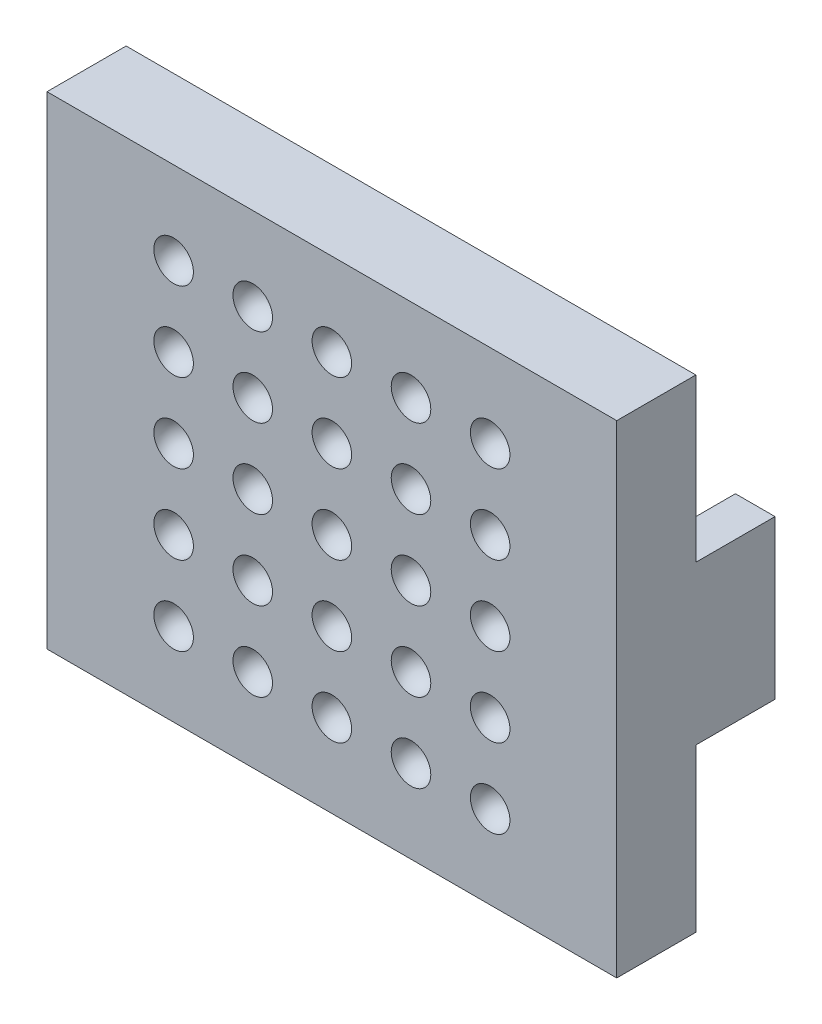
from build123d import *

# Parameters (mm, degrees)
SKETCH1_W                  = 72
SKETCH1_H                  = 61
MOLD_TOP_DEPTH             = 10
SKETCH3_W                  = 5
SKETCH3_H                  = 20
HANDLE_1_DEPTH             = 10
LPATTERN1_COUNT            = 3
LPATTERN1_PITCH            = 10
LPATTERN1_COUNT_DIR2       = 3
LPATTERN1_PITCH_DIR2       = 10
LPATTERN2_COUNT            = 3
LPATTERN2_PITCH            = 10
LPATTERN2_COUNT_DIR2       = 3
LPATTERN2_PITCH_DIR2       = 10
SKETCH6_R                  = 0.5
CUT_EXTRUDE1_DEPTH         = 21
LPATTERN3_COUNT            = 3
LPATTERN3_PITCH            = 10
LPATTERN3_COUNT_DIR2       = 3
LPATTERN3_PITCH_DIR2       = 10
LPATTERN4_COUNT            = 3
LPATTERN4_PITCH            = 10
LPATTERN4_COUNT_DIR2       = 3
LPATTERN4_PITCH_DIR2       = 10
LPATTERN4_COPY_1_SKETCH_R  = 0.5
LPATTERN4_COPY_1_DEPTH     = 21
LPATTERN4_COPY_2_SKETCH_R  = 0.5
LPATTERN4_COPY_2_DEPTH     = 21
LPATTERN4_COPY_3_SKETCH_R  = 0.5
LPATTERN4_COPY_3_DEPTH     = 21
LPATTERN4_COPY_4_SKETCH_R  = 0.5
LPATTERN4_COPY_4_DEPTH     = 21
LPATTERN4_COPY_5_SKETCH_R  = 0.5
LPATTERN4_COPY_5_DEPTH     = 21
LPATTERN4_COPY_6_SKETCH_R  = 0.5
LPATTERN4_COPY_6_DEPTH     = 21
LPATTERN4_COPY_7_SKETCH_R  = 0.5
LPATTERN4_COPY_7_DEPTH     = 21
LPATTERN4_COPY_8_SKETCH_R  = 0.5
LPATTERN4_COPY_8_DEPTH     = 21
LPATTERN4_COPY_9_SKETCH_R  = 0.5
LPATTERN4_COPY_9_DEPTH     = 21
LPATTERN4_COPY_10_SKETCH_R = 0.5
LPATTERN4_COPY_10_DEPTH    = 21
LPATTERN4_COPY_11_SKETCH_R = 0.5
LPATTERN4_COPY_11_DEPTH    = 21
LPATTERN4_COPY_12_SKETCH_R = 0.5
LPATTERN4_COPY_12_DEPTH    = 21
LPATTERN4_COPY_13_SKETCH_R = 0.5
LPATTERN4_COPY_13_DEPTH    = 21
LPATTERN4_COPY_14_SKETCH_R = 0.5
LPATTERN4_COPY_14_DEPTH    = 21
LPATTERN4_COPY_15_SKETCH_R = 0.5
LPATTERN4_COPY_15_DEPTH    = 21
LPATTERN4_COPY_16_SKETCH_R = 0.5
LPATTERN4_COPY_16_DEPTH    = 21
LPATTERN4_COPY_17_SKETCH_R = 0.5
LPATTERN4_COPY_17_DEPTH    = 21
LPATTERN4_COPY_18_SKETCH_R = 0.5
LPATTERN4_COPY_18_DEPTH    = 21
LPATTERN4_COPY_19_SKETCH_R = 0.5
LPATTERN4_COPY_19_DEPTH    = 21
LPATTERN4_COPY_20_SKETCH_R = 0.5
LPATTERN4_COPY_20_DEPTH    = 21
LPATTERN4_COPY_21_SKETCH_R = 0.5
LPATTERN4_COPY_21_DEPTH    = 21
LPATTERN4_COPY_22_SKETCH_R = 0.5
LPATTERN4_COPY_22_DEPTH    = 21
LPATTERN4_COPY_23_SKETCH_R = 0.5
LPATTERN4_COPY_23_DEPTH    = 21
LPATTERN4_COPY_24_SKETCH_R = 0.5
LPATTERN4_COPY_24_DEPTH    = 21
LPATTERN4_COPY_25_SKETCH_R = 0.5
LPATTERN4_COPY_25_DEPTH    = 21
LPATTERN4_COPY_26_SKETCH_R = 0.5
LPATTERN4_COPY_26_DEPTH    = 21
LPATTERN4_COPY_27_SKETCH_R = 0.5
LPATTERN4_COPY_27_DEPTH    = 21
LPATTERN4_COPY_28_SKETCH_R = 0.5
LPATTERN4_COPY_28_DEPTH    = 21
LPATTERN4_COPY_29_SKETCH_R = 0.5
LPATTERN4_COPY_29_DEPTH    = 21
LPATTERN4_COPY_30_SKETCH_R = 0.5
LPATTERN4_COPY_30_DEPTH    = 21
LPATTERN4_COPY_31_SKETCH_R = 0.5
LPATTERN4_COPY_31_DEPTH    = 21
LPATTERN4_COPY_32_SKETCH_R = 0.5
LPATTERN4_COPY_32_DEPTH    = 21
LPATTERN4_COPY_33_SKETCH_R = 0.5
LPATTERN4_COPY_33_DEPTH    = 21
LPATTERN4_COPY_34_SKETCH_R = 0.5
LPATTERN4_COPY_34_DEPTH    = 21
LPATTERN4_COPY_35_SKETCH_R = 0.5
LPATTERN4_COPY_35_DEPTH    = 21
LPATTERN4_COPY_36_SKETCH_R = 0.5
LPATTERN4_COPY_36_DEPTH    = 21
LPATTERN4_COPY_37_SKETCH_R = 0.5
LPATTERN4_COPY_37_DEPTH    = 21
LPATTERN4_COPY_38_SKETCH_R = 0.5
LPATTERN4_COPY_38_DEPTH    = 21
LPATTERN4_COPY_39_SKETCH_R = 0.5
LPATTERN4_COPY_39_DEPTH    = 21
LPATTERN4_COPY_40_SKETCH_R = 0.5
LPATTERN4_COPY_40_DEPTH    = 21
LPATTERN4_COPY_41_SKETCH_R = 0.5
LPATTERN4_COPY_41_DEPTH    = 21
LPATTERN4_COPY_42_SKETCH_R = 0.5
LPATTERN4_COPY_42_DEPTH    = 21
LPATTERN4_COPY_43_SKETCH_R = 0.5
LPATTERN4_COPY_43_DEPTH    = 21
LPATTERN4_COPY_44_SKETCH_R = 0.5
LPATTERN4_COPY_44_DEPTH    = 21
LPATTERN4_COPY_45_SKETCH_R = 0.5
LPATTERN4_COPY_45_DEPTH    = 21
LPATTERN4_COPY_46_SKETCH_R = 0.5
LPATTERN4_COPY_46_DEPTH    = 21
LPATTERN4_COPY_47_SKETCH_R = 0.5
LPATTERN4_COPY_47_DEPTH    = 21
LPATTERN4_COPY_48_SKETCH_R = 0.5
LPATTERN4_COPY_48_DEPTH    = 21
LPATTERN4_COPY_49_SKETCH_R = 0.5
LPATTERN4_COPY_49_DEPTH    = 21
LPATTERN4_COPY_50_SKETCH_R = 0.5
LPATTERN4_COPY_50_DEPTH    = 21
LPATTERN4_COPY_51_SKETCH_R = 0.5
LPATTERN4_COPY_51_DEPTH    = 21
LPATTERN4_COPY_52_SKETCH_R = 0.5
LPATTERN4_COPY_52_DEPTH    = 21
LPATTERN4_COPY_53_SKETCH_R = 0.5
LPATTERN4_COPY_53_DEPTH    = 21
LPATTERN4_COPY_54_SKETCH_R = 0.5
LPATTERN4_COPY_54_DEPTH    = 21
LPATTERN4_COPY_55_SKETCH_R = 0.5
LPATTERN4_COPY_55_DEPTH    = 21
LPATTERN4_COPY_56_SKETCH_R = 0.5
LPATTERN4_COPY_56_DEPTH    = 21
LPATTERN4_COPY_57_SKETCH_R = 0.5
LPATTERN4_COPY_57_DEPTH    = 21
LPATTERN4_COPY_58_SKETCH_R = 0.5
LPATTERN4_COPY_58_DEPTH    = 21
LPATTERN4_COPY_59_SKETCH_R = 0.5
LPATTERN4_COPY_59_DEPTH    = 21
LPATTERN4_COPY_60_SKETCH_R = 0.5
LPATTERN4_COPY_60_DEPTH    = 21
LPATTERN4_COPY_61_SKETCH_R = 0.5
LPATTERN4_COPY_61_DEPTH    = 21
LPATTERN4_COPY_62_SKETCH_R = 0.5
LPATTERN4_COPY_62_DEPTH    = 21
LPATTERN4_COPY_63_SKETCH_R = 0.5
LPATTERN4_COPY_63_DEPTH    = 21
LPATTERN4_COPY_64_SKETCH_R = 0.5
LPATTERN4_COPY_64_DEPTH    = 21


with BuildPart() as part:
    # Sketch1 → Mold Top (new body)
    with BuildSketch(Plane.XY):
        Rectangle(SKETCH1_W, SKETCH1_H)
    extrude(amount=MOLD_TOP_DEPTH)

    # Sketch3 → Handle 1 (add)
    with BuildSketch(Plane(origin=(0, 0, 0), x_dir=(-1, 0, 0), z_dir=(0, 0, -1))):
        with Locations((-33.5, 0)):
            Rectangle(SKETCH3_W, SKETCH3_H)
    handle_1 = extrude(amount=HANDLE_1_DEPTH)

    # Handle 2: Handle 1 across plane
    add(handle_1.mirror(Plane(origin=(0, 0, 0), x_dir=(0, 0, 1), z_dir=(1, 0, 0))))

    # Sketch5 → Cut-Revolve1 (revolve, cut)
    with BuildSketch(Plane.XY.offset(10)):
        with BuildLine():
            Line((0, 2.5), (0, -2.5))
            ThreePointArc((0, -2.5), (2.5, 0), (0, 2.5))
        make_face()
    cut_revolve1 = revolve(axis=Axis((0, 2.5, 10), (0, -1, 0)), mode=Mode.SUBTRACT)

    # LPattern1: Cut-Revolve1 3 × 3
    with Locations(*[(-j * LPATTERN1_PITCH_DIR2, -i * LPATTERN1_PITCH, 0) for i in range(LPATTERN1_COUNT) for j in range(LPATTERN1_COUNT_DIR2) if (i, j) != (0, 0)]):
        add(cut_revolve1, mode=Mode.SUBTRACT)

    # LPattern2: Cut-Revolve1 3 × 3
    with Locations(*[(i * LPATTERN2_PITCH, j * LPATTERN2_PITCH_DIR2, 0) for i in range(LPATTERN2_COUNT) for j in range(LPATTERN2_COUNT_DIR2) if (i, j) != (0, 0)]):
        add(cut_revolve1, mode=Mode.SUBTRACT)

    # LPattern2 copy 1 sketch → LPattern2 copy 1 (revolve, cut)
    with BuildSketch(Plane(origin=(-10, 10, 10), x_dir=(1, 0, 0), z_dir=(0, 0, 1))):
        with BuildLine():
            Line((0, 2.5), (0, -2.5))
            ThreePointArc((0, -2.5), (2.5, 0), (0, 2.5))
        make_face()
    revolve(axis=Axis((-10, 12.5, 10), (0, -1, 0)), mode=Mode.SUBTRACT)

    # LPattern2 copy 2 sketch → LPattern2 copy 2 (revolve, cut)
    with BuildSketch(Plane(origin=(-10, 20, 10), x_dir=(1, 0, 0), z_dir=(0, 0, 1))):
        with BuildLine():
            Line((0, 2.5), (0, -2.5))
            ThreePointArc((0, -2.5), (2.5, 0), (0, 2.5))
        make_face()
    revolve(axis=Axis((-10, 22.5, 10), (0, -1, 0)), mode=Mode.SUBTRACT)

    # LPattern2 copy 3 sketch → LPattern2 copy 3 (revolve, cut)
    with BuildSketch(Plane.XY.offset(10)):
        with BuildLine():
            Line((0, 2.5), (0, -2.5))
            ThreePointArc((0, -2.5), (2.5, 0), (0, 2.5))
        make_face()
    revolve(axis=Axis((0, 2.5, 10), (0, -1, 0)), mode=Mode.SUBTRACT)

    # LPattern2 copy 4 sketch → LPattern2 copy 4 (revolve, cut)
    with BuildSketch(Plane(origin=(0, 10, 10), x_dir=(1, 0, 0), z_dir=(0, 0, 1))):
        with BuildLine():
            Line((0, 2.5), (0, -2.5))
            ThreePointArc((0, -2.5), (2.5, 0), (0, 2.5))
        make_face()
    revolve(axis=Axis((0, 12.5, 10), (0, -1, 0)), mode=Mode.SUBTRACT)

    # LPattern2 copy 5 sketch → LPattern2 copy 5 (revolve, cut)
    with BuildSketch(Plane(origin=(0, 20, 10), x_dir=(1, 0, 0), z_dir=(0, 0, 1))):
        with BuildLine():
            Line((0, 2.5), (0, -2.5))
            ThreePointArc((0, -2.5), (2.5, 0), (0, 2.5))
        make_face()
    revolve(axis=Axis((0, 22.5, 10), (0, -1, 0)), mode=Mode.SUBTRACT)

    # LPattern2 copy 6 sketch → LPattern2 copy 6 (revolve, cut)
    with BuildSketch(Plane(origin=(10, 0, 10), x_dir=(1, 0, 0), z_dir=(0, 0, 1))):
        with BuildLine():
            Line((0, 2.5), (0, -2.5))
            ThreePointArc((0, -2.5), (2.5, 0), (0, 2.5))
        make_face()
    revolve(axis=Axis((10, 2.5, 10), (0, -1, 0)), mode=Mode.SUBTRACT)

    # LPattern2 copy 7 sketch → LPattern2 copy 7 (revolve, cut)
    with BuildSketch(Plane(origin=(10, 10, 10), x_dir=(1, 0, 0), z_dir=(0, 0, 1))):
        with BuildLine():
            Line((0, 2.5), (0, -2.5))
            ThreePointArc((0, -2.5), (2.5, 0), (0, 2.5))
        make_face()
    revolve(axis=Axis((10, 12.5, 10), (0, -1, 0)), mode=Mode.SUBTRACT)

    # LPattern2 copy 8 sketch → LPattern2 copy 8 (revolve, cut)
    with BuildSketch(Plane(origin=(10, 20, 10), x_dir=(1, 0, 0), z_dir=(0, 0, 1))):
        with BuildLine():
            Line((0, 2.5), (0, -2.5))
            ThreePointArc((0, -2.5), (2.5, 0), (0, 2.5))
        make_face()
    revolve(axis=Axis((10, 22.5, 10), (0, -1, 0)), mode=Mode.SUBTRACT)

    # LPattern2 copy 9 sketch → LPattern2 copy 9 (revolve, cut)
    with BuildSketch(Plane(origin=(-20, 10, 10), x_dir=(1, 0, 0), z_dir=(0, 0, 1))):
        with BuildLine():
            Line((0, 2.5), (0, -2.5))
            ThreePointArc((0, -2.5), (2.5, 0), (0, 2.5))
        make_face()
    revolve(axis=Axis((-20, 12.5, 10), (0, -1, 0)), mode=Mode.SUBTRACT)

    # LPattern2 copy 10 sketch → LPattern2 copy 10 (revolve, cut)
    with BuildSketch(Plane(origin=(-20, 20, 10), x_dir=(1, 0, 0), z_dir=(0, 0, 1))):
        with BuildLine():
            Line((0, 2.5), (0, -2.5))
            ThreePointArc((0, -2.5), (2.5, 0), (0, 2.5))
        make_face()
    revolve(axis=Axis((-20, 22.5, 10), (0, -1, 0)), mode=Mode.SUBTRACT)

    # LPattern2 copy 11 sketch → LPattern2 copy 11 (revolve, cut)
    with BuildSketch(Plane(origin=(-10, 0, 10), x_dir=(1, 0, 0), z_dir=(0, 0, 1))):
        with BuildLine():
            Line((0, 2.5), (0, -2.5))
            ThreePointArc((0, -2.5), (2.5, 0), (0, 2.5))
        make_face()
    revolve(axis=Axis((-10, 2.5, 10), (0, -1, 0)), mode=Mode.SUBTRACT)

    # LPattern2 copy 12 sketch → LPattern2 copy 12 (revolve, cut)
    with BuildSketch(Plane(origin=(-10, 10, 10), x_dir=(1, 0, 0), z_dir=(0, 0, 1))):
        with BuildLine():
            Line((0, 2.5), (0, -2.5))
            ThreePointArc((0, -2.5), (2.5, 0), (0, 2.5))
        make_face()
    revolve(axis=Axis((-10, 12.5, 10), (0, -1, 0)), mode=Mode.SUBTRACT)

    # LPattern2 copy 13 sketch → LPattern2 copy 13 (revolve, cut)
    with BuildSketch(Plane(origin=(-10, 20, 10), x_dir=(1, 0, 0), z_dir=(0, 0, 1))):
        with BuildLine():
            Line((0, 2.5), (0, -2.5))
            ThreePointArc((0, -2.5), (2.5, 0), (0, 2.5))
        make_face()
    revolve(axis=Axis((-10, 22.5, 10), (0, -1, 0)), mode=Mode.SUBTRACT)

    # LPattern2 copy 14 sketch → LPattern2 copy 14 (revolve, cut)
    with BuildSketch(Plane.XY.offset(10)):
        with BuildLine():
            Line((0, 2.5), (0, -2.5))
            ThreePointArc((0, -2.5), (2.5, 0), (0, 2.5))
        make_face()
    revolve(axis=Axis((0, 2.5, 10), (0, -1, 0)), mode=Mode.SUBTRACT)

    # LPattern2 copy 15 sketch → LPattern2 copy 15 (revolve, cut)
    with BuildSketch(Plane(origin=(0, 10, 10), x_dir=(1, 0, 0), z_dir=(0, 0, 1))):
        with BuildLine():
            Line((0, 2.5), (0, -2.5))
            ThreePointArc((0, -2.5), (2.5, 0), (0, 2.5))
        make_face()
    revolve(axis=Axis((0, 12.5, 10), (0, -1, 0)), mode=Mode.SUBTRACT)

    # LPattern2 copy 16 sketch → LPattern2 copy 16 (revolve, cut)
    with BuildSketch(Plane(origin=(0, 20, 10), x_dir=(1, 0, 0), z_dir=(0, 0, 1))):
        with BuildLine():
            Line((0, 2.5), (0, -2.5))
            ThreePointArc((0, -2.5), (2.5, 0), (0, 2.5))
        make_face()
    revolve(axis=Axis((0, 22.5, 10), (0, -1, 0)), mode=Mode.SUBTRACT)

    # LPattern2 copy 17 sketch → LPattern2 copy 17 (revolve, cut)
    with BuildSketch(Plane.XY.offset(10)):
        with BuildLine():
            Line((0, 2.5), (0, -2.5))
            ThreePointArc((0, -2.5), (2.5, 0), (0, 2.5))
        make_face()
    revolve(axis=Axis((0, 2.5, 10), (0, -1, 0)), mode=Mode.SUBTRACT)

    # LPattern2 copy 18 sketch → LPattern2 copy 18 (revolve, cut)
    with BuildSketch(Plane(origin=(0, 10, 10), x_dir=(1, 0, 0), z_dir=(0, 0, 1))):
        with BuildLine():
            Line((0, 2.5), (0, -2.5))
            ThreePointArc((0, -2.5), (2.5, 0), (0, 2.5))
        make_face()
    revolve(axis=Axis((0, 12.5, 10), (0, -1, 0)), mode=Mode.SUBTRACT)

    # LPattern2 copy 19 sketch → LPattern2 copy 19 (revolve, cut)
    with BuildSketch(Plane(origin=(10, -10, 10), x_dir=(1, 0, 0), z_dir=(0, 0, 1))):
        with BuildLine():
            Line((0, 2.5), (0, -2.5))
            ThreePointArc((0, -2.5), (2.5, 0), (0, 2.5))
        make_face()
    revolve(axis=Axis((10, -7.5, 10), (0, -1, 0)), mode=Mode.SUBTRACT)

    # LPattern2 copy 20 sketch → LPattern2 copy 20 (revolve, cut)
    with BuildSketch(Plane(origin=(10, 0, 10), x_dir=(1, 0, 0), z_dir=(0, 0, 1))):
        with BuildLine():
            Line((0, 2.5), (0, -2.5))
            ThreePointArc((0, -2.5), (2.5, 0), (0, 2.5))
        make_face()
    revolve(axis=Axis((10, 2.5, 10), (0, -1, 0)), mode=Mode.SUBTRACT)

    # LPattern2 copy 21 sketch → LPattern2 copy 21 (revolve, cut)
    with BuildSketch(Plane(origin=(10, 10, 10), x_dir=(1, 0, 0), z_dir=(0, 0, 1))):
        with BuildLine():
            Line((0, 2.5), (0, -2.5))
            ThreePointArc((0, -2.5), (2.5, 0), (0, 2.5))
        make_face()
    revolve(axis=Axis((10, 12.5, 10), (0, -1, 0)), mode=Mode.SUBTRACT)

    # LPattern2 copy 22 sketch → LPattern2 copy 22 (revolve, cut)
    with BuildSketch(Plane(origin=(20, -10, 10), x_dir=(1, 0, 0), z_dir=(0, 0, 1))):
        with BuildLine():
            Line((0, 2.5), (0, -2.5))
            ThreePointArc((0, -2.5), (2.5, 0), (0, 2.5))
        make_face()
    revolve(axis=Axis((20, -7.5, 10), (0, -1, 0)), mode=Mode.SUBTRACT)

    # LPattern2 copy 23 sketch → LPattern2 copy 23 (revolve, cut)
    with BuildSketch(Plane(origin=(20, 0, 10), x_dir=(1, 0, 0), z_dir=(0, 0, 1))):
        with BuildLine():
            Line((0, 2.5), (0, -2.5))
            ThreePointArc((0, -2.5), (2.5, 0), (0, 2.5))
        make_face()
    revolve(axis=Axis((20, 2.5, 10), (0, -1, 0)), mode=Mode.SUBTRACT)

    # LPattern2 copy 24 sketch → LPattern2 copy 24 (revolve, cut)
    with BuildSketch(Plane(origin=(20, 10, 10), x_dir=(1, 0, 0), z_dir=(0, 0, 1))):
        with BuildLine():
            Line((0, 2.5), (0, -2.5))
            ThreePointArc((0, -2.5), (2.5, 0), (0, 2.5))
        make_face()
    revolve(axis=Axis((20, 12.5, 10), (0, -1, 0)), mode=Mode.SUBTRACT)

    # LPattern2 copy 25 sketch → LPattern2 copy 25 (revolve, cut)
    with BuildSketch(Plane(origin=(-10, 0, 10), x_dir=(1, 0, 0), z_dir=(0, 0, 1))):
        with BuildLine():
            Line((0, 2.5), (0, -2.5))
            ThreePointArc((0, -2.5), (2.5, 0), (0, 2.5))
        make_face()
    revolve(axis=Axis((-10, 2.5, 10), (0, -1, 0)), mode=Mode.SUBTRACT)

    # LPattern2 copy 26 sketch → LPattern2 copy 26 (revolve, cut)
    with BuildSketch(Plane(origin=(-10, 10, 10), x_dir=(1, 0, 0), z_dir=(0, 0, 1))):
        with BuildLine():
            Line((0, 2.5), (0, -2.5))
            ThreePointArc((0, -2.5), (2.5, 0), (0, 2.5))
        make_face()
    revolve(axis=Axis((-10, 12.5, 10), (0, -1, 0)), mode=Mode.SUBTRACT)

    # LPattern2 copy 27 sketch → LPattern2 copy 27 (revolve, cut)
    with BuildSketch(Plane(origin=(0, -10, 10), x_dir=(1, 0, 0), z_dir=(0, 0, 1))):
        with BuildLine():
            Line((0, 2.5), (0, -2.5))
            ThreePointArc((0, -2.5), (2.5, 0), (0, 2.5))
        make_face()
    revolve(axis=Axis((0, -7.5, 10), (0, -1, 0)), mode=Mode.SUBTRACT)

    # LPattern2 copy 28 sketch → LPattern2 copy 28 (revolve, cut)
    with BuildSketch(Plane.XY.offset(10)):
        with BuildLine():
            Line((0, 2.5), (0, -2.5))
            ThreePointArc((0, -2.5), (2.5, 0), (0, 2.5))
        make_face()
    revolve(axis=Axis((0, 2.5, 10), (0, -1, 0)), mode=Mode.SUBTRACT)

    # LPattern2 copy 29 sketch → LPattern2 copy 29 (revolve, cut)
    with BuildSketch(Plane(origin=(0, 10, 10), x_dir=(1, 0, 0), z_dir=(0, 0, 1))):
        with BuildLine():
            Line((0, 2.5), (0, -2.5))
            ThreePointArc((0, -2.5), (2.5, 0), (0, 2.5))
        make_face()
    revolve(axis=Axis((0, 12.5, 10), (0, -1, 0)), mode=Mode.SUBTRACT)

    # LPattern2 copy 30 sketch → LPattern2 copy 30 (revolve, cut)
    with BuildSketch(Plane(origin=(10, -10, 10), x_dir=(1, 0, 0), z_dir=(0, 0, 1))):
        with BuildLine():
            Line((0, 2.5), (0, -2.5))
            ThreePointArc((0, -2.5), (2.5, 0), (0, 2.5))
        make_face()
    revolve(axis=Axis((10, -7.5, 10), (0, -1, 0)), mode=Mode.SUBTRACT)

    # LPattern2 copy 31 sketch → LPattern2 copy 31 (revolve, cut)
    with BuildSketch(Plane(origin=(10, 0, 10), x_dir=(1, 0, 0), z_dir=(0, 0, 1))):
        with BuildLine():
            Line((0, 2.5), (0, -2.5))
            ThreePointArc((0, -2.5), (2.5, 0), (0, 2.5))
        make_face()
    revolve(axis=Axis((10, 2.5, 10), (0, -1, 0)), mode=Mode.SUBTRACT)

    # LPattern2 copy 32 sketch → LPattern2 copy 32 (revolve, cut)
    with BuildSketch(Plane(origin=(10, 10, 10), x_dir=(1, 0, 0), z_dir=(0, 0, 1))):
        with BuildLine():
            Line((0, 2.5), (0, -2.5))
            ThreePointArc((0, -2.5), (2.5, 0), (0, 2.5))
        make_face()
    revolve(axis=Axis((10, 12.5, 10), (0, -1, 0)), mode=Mode.SUBTRACT)

    # LPattern2 copy 33 sketch → LPattern2 copy 33 (revolve, cut)
    with BuildSketch(Plane(origin=(-20, 0, 10), x_dir=(1, 0, 0), z_dir=(0, 0, 1))):
        with BuildLine():
            Line((0, 2.5), (0, -2.5))
            ThreePointArc((0, -2.5), (2.5, 0), (0, 2.5))
        make_face()
    revolve(axis=Axis((-20, 2.5, 10), (0, -1, 0)), mode=Mode.SUBTRACT)

    # LPattern2 copy 34 sketch → LPattern2 copy 34 (revolve, cut)
    with BuildSketch(Plane(origin=(-20, 10, 10), x_dir=(1, 0, 0), z_dir=(0, 0, 1))):
        with BuildLine():
            Line((0, 2.5), (0, -2.5))
            ThreePointArc((0, -2.5), (2.5, 0), (0, 2.5))
        make_face()
    revolve(axis=Axis((-20, 12.5, 10), (0, -1, 0)), mode=Mode.SUBTRACT)

    # LPattern2 copy 35 sketch → LPattern2 copy 35 (revolve, cut)
    with BuildSketch(Plane(origin=(-10, -10, 10), x_dir=(1, 0, 0), z_dir=(0, 0, 1))):
        with BuildLine():
            Line((0, 2.5), (0, -2.5))
            ThreePointArc((0, -2.5), (2.5, 0), (0, 2.5))
        make_face()
    revolve(axis=Axis((-10, -7.5, 10), (0, -1, 0)), mode=Mode.SUBTRACT)

    # LPattern2 copy 36 sketch → LPattern2 copy 36 (revolve, cut)
    with BuildSketch(Plane(origin=(-10, 0, 10), x_dir=(1, 0, 0), z_dir=(0, 0, 1))):
        with BuildLine():
            Line((0, 2.5), (0, -2.5))
            ThreePointArc((0, -2.5), (2.5, 0), (0, 2.5))
        make_face()
    revolve(axis=Axis((-10, 2.5, 10), (0, -1, 0)), mode=Mode.SUBTRACT)

    # LPattern2 copy 37 sketch → LPattern2 copy 37 (revolve, cut)
    with BuildSketch(Plane(origin=(-10, 10, 10), x_dir=(1, 0, 0), z_dir=(0, 0, 1))):
        with BuildLine():
            Line((0, 2.5), (0, -2.5))
            ThreePointArc((0, -2.5), (2.5, 0), (0, 2.5))
        make_face()
    revolve(axis=Axis((-10, 12.5, 10), (0, -1, 0)), mode=Mode.SUBTRACT)

    # LPattern2 copy 38 sketch → LPattern2 copy 38 (revolve, cut)
    with BuildSketch(Plane(origin=(0, -10, 10), x_dir=(1, 0, 0), z_dir=(0, 0, 1))):
        with BuildLine():
            Line((0, 2.5), (0, -2.5))
            ThreePointArc((0, -2.5), (2.5, 0), (0, 2.5))
        make_face()
    revolve(axis=Axis((0, -7.5, 10), (0, -1, 0)), mode=Mode.SUBTRACT)

    # LPattern2 copy 39 sketch → LPattern2 copy 39 (revolve, cut)
    with BuildSketch(Plane.XY.offset(10)):
        with BuildLine():
            Line((0, 2.5), (0, -2.5))
            ThreePointArc((0, -2.5), (2.5, 0), (0, 2.5))
        make_face()
    revolve(axis=Axis((0, 2.5, 10), (0, -1, 0)), mode=Mode.SUBTRACT)

    # LPattern2 copy 40 sketch → LPattern2 copy 40 (revolve, cut)
    with BuildSketch(Plane(origin=(0, 10, 10), x_dir=(1, 0, 0), z_dir=(0, 0, 1))):
        with BuildLine():
            Line((0, 2.5), (0, -2.5))
            ThreePointArc((0, -2.5), (2.5, 0), (0, 2.5))
        make_face()
    revolve(axis=Axis((0, 12.5, 10), (0, -1, 0)), mode=Mode.SUBTRACT)

    # LPattern2 copy 41 sketch → LPattern2 copy 41 (revolve, cut)
    with BuildSketch(Plane(origin=(0, -10, 10), x_dir=(1, 0, 0), z_dir=(0, 0, 1))):
        with BuildLine():
            Line((0, 2.5), (0, -2.5))
            ThreePointArc((0, -2.5), (2.5, 0), (0, 2.5))
        make_face()
    revolve(axis=Axis((0, -7.5, 10), (0, -1, 0)), mode=Mode.SUBTRACT)

    # LPattern2 copy 42 sketch → LPattern2 copy 42 (revolve, cut)
    with BuildSketch(Plane.XY.offset(10)):
        with BuildLine():
            Line((0, 2.5), (0, -2.5))
            ThreePointArc((0, -2.5), (2.5, 0), (0, 2.5))
        make_face()
    revolve(axis=Axis((0, 2.5, 10), (0, -1, 0)), mode=Mode.SUBTRACT)

    # LPattern2 copy 43 sketch → LPattern2 copy 43 (revolve, cut)
    with BuildSketch(Plane(origin=(10, -20, 10), x_dir=(1, 0, 0), z_dir=(0, 0, 1))):
        with BuildLine():
            Line((0, 2.5), (0, -2.5))
            ThreePointArc((0, -2.5), (2.5, 0), (0, 2.5))
        make_face()
    revolve(axis=Axis((10, -17.5, 10), (0, -1, 0)), mode=Mode.SUBTRACT)

    # LPattern2 copy 44 sketch → LPattern2 copy 44 (revolve, cut)
    with BuildSketch(Plane(origin=(10, -10, 10), x_dir=(1, 0, 0), z_dir=(0, 0, 1))):
        with BuildLine():
            Line((0, 2.5), (0, -2.5))
            ThreePointArc((0, -2.5), (2.5, 0), (0, 2.5))
        make_face()
    revolve(axis=Axis((10, -7.5, 10), (0, -1, 0)), mode=Mode.SUBTRACT)

    # LPattern2 copy 45 sketch → LPattern2 copy 45 (revolve, cut)
    with BuildSketch(Plane(origin=(10, 0, 10), x_dir=(1, 0, 0), z_dir=(0, 0, 1))):
        with BuildLine():
            Line((0, 2.5), (0, -2.5))
            ThreePointArc((0, -2.5), (2.5, 0), (0, 2.5))
        make_face()
    revolve(axis=Axis((10, 2.5, 10), (0, -1, 0)), mode=Mode.SUBTRACT)

    # LPattern2 copy 46 sketch → LPattern2 copy 46 (revolve, cut)
    with BuildSketch(Plane(origin=(20, -20, 10), x_dir=(1, 0, 0), z_dir=(0, 0, 1))):
        with BuildLine():
            Line((0, 2.5), (0, -2.5))
            ThreePointArc((0, -2.5), (2.5, 0), (0, 2.5))
        make_face()
    revolve(axis=Axis((20, -17.5, 10), (0, -1, 0)), mode=Mode.SUBTRACT)

    # LPattern2 copy 47 sketch → LPattern2 copy 47 (revolve, cut)
    with BuildSketch(Plane(origin=(20, -10, 10), x_dir=(1, 0, 0), z_dir=(0, 0, 1))):
        with BuildLine():
            Line((0, 2.5), (0, -2.5))
            ThreePointArc((0, -2.5), (2.5, 0), (0, 2.5))
        make_face()
    revolve(axis=Axis((20, -7.5, 10), (0, -1, 0)), mode=Mode.SUBTRACT)

    # LPattern2 copy 48 sketch → LPattern2 copy 48 (revolve, cut)
    with BuildSketch(Plane(origin=(20, 0, 10), x_dir=(1, 0, 0), z_dir=(0, 0, 1))):
        with BuildLine():
            Line((0, 2.5), (0, -2.5))
            ThreePointArc((0, -2.5), (2.5, 0), (0, 2.5))
        make_face()
    revolve(axis=Axis((20, 2.5, 10), (0, -1, 0)), mode=Mode.SUBTRACT)

    # LPattern2 copy 49 sketch → LPattern2 copy 49 (revolve, cut)
    with BuildSketch(Plane(origin=(-10, -10, 10), x_dir=(1, 0, 0), z_dir=(0, 0, 1))):
        with BuildLine():
            Line((0, 2.5), (0, -2.5))
            ThreePointArc((0, -2.5), (2.5, 0), (0, 2.5))
        make_face()
    revolve(axis=Axis((-10, -7.5, 10), (0, -1, 0)), mode=Mode.SUBTRACT)

    # LPattern2 copy 50 sketch → LPattern2 copy 50 (revolve, cut)
    with BuildSketch(Plane(origin=(-10, 0, 10), x_dir=(1, 0, 0), z_dir=(0, 0, 1))):
        with BuildLine():
            Line((0, 2.5), (0, -2.5))
            ThreePointArc((0, -2.5), (2.5, 0), (0, 2.5))
        make_face()
    revolve(axis=Axis((-10, 2.5, 10), (0, -1, 0)), mode=Mode.SUBTRACT)

    # LPattern2 copy 51 sketch → LPattern2 copy 51 (revolve, cut)
    with BuildSketch(Plane(origin=(0, -20, 10), x_dir=(1, 0, 0), z_dir=(0, 0, 1))):
        with BuildLine():
            Line((0, 2.5), (0, -2.5))
            ThreePointArc((0, -2.5), (2.5, 0), (0, 2.5))
        make_face()
    revolve(axis=Axis((0, -17.5, 10), (0, -1, 0)), mode=Mode.SUBTRACT)

    # LPattern2 copy 52 sketch → LPattern2 copy 52 (revolve, cut)
    with BuildSketch(Plane(origin=(0, -10, 10), x_dir=(1, 0, 0), z_dir=(0, 0, 1))):
        with BuildLine():
            Line((0, 2.5), (0, -2.5))
            ThreePointArc((0, -2.5), (2.5, 0), (0, 2.5))
        make_face()
    revolve(axis=Axis((0, -7.5, 10), (0, -1, 0)), mode=Mode.SUBTRACT)

    # LPattern2 copy 53 sketch → LPattern2 copy 53 (revolve, cut)
    with BuildSketch(Plane.XY.offset(10)):
        with BuildLine():
            Line((0, 2.5), (0, -2.5))
            ThreePointArc((0, -2.5), (2.5, 0), (0, 2.5))
        make_face()
    revolve(axis=Axis((0, 2.5, 10), (0, -1, 0)), mode=Mode.SUBTRACT)

    # LPattern2 copy 54 sketch → LPattern2 copy 54 (revolve, cut)
    with BuildSketch(Plane(origin=(10, -20, 10), x_dir=(1, 0, 0), z_dir=(0, 0, 1))):
        with BuildLine():
            Line((0, 2.5), (0, -2.5))
            ThreePointArc((0, -2.5), (2.5, 0), (0, 2.5))
        make_face()
    revolve(axis=Axis((10, -17.5, 10), (0, -1, 0)), mode=Mode.SUBTRACT)

    # LPattern2 copy 55 sketch → LPattern2 copy 55 (revolve, cut)
    with BuildSketch(Plane(origin=(10, -10, 10), x_dir=(1, 0, 0), z_dir=(0, 0, 1))):
        with BuildLine():
            Line((0, 2.5), (0, -2.5))
            ThreePointArc((0, -2.5), (2.5, 0), (0, 2.5))
        make_face()
    revolve(axis=Axis((10, -7.5, 10), (0, -1, 0)), mode=Mode.SUBTRACT)

    # LPattern2 copy 56 sketch → LPattern2 copy 56 (revolve, cut)
    with BuildSketch(Plane(origin=(10, 0, 10), x_dir=(1, 0, 0), z_dir=(0, 0, 1))):
        with BuildLine():
            Line((0, 2.5), (0, -2.5))
            ThreePointArc((0, -2.5), (2.5, 0), (0, 2.5))
        make_face()
    revolve(axis=Axis((10, 2.5, 10), (0, -1, 0)), mode=Mode.SUBTRACT)

    # LPattern2 copy 57 sketch → LPattern2 copy 57 (revolve, cut)
    with BuildSketch(Plane(origin=(-20, -10, 10), x_dir=(1, 0, 0), z_dir=(0, 0, 1))):
        with BuildLine():
            Line((0, 2.5), (0, -2.5))
            ThreePointArc((0, -2.5), (2.5, 0), (0, 2.5))
        make_face()
    revolve(axis=Axis((-20, -7.5, 10), (0, -1, 0)), mode=Mode.SUBTRACT)

    # LPattern2 copy 58 sketch → LPattern2 copy 58 (revolve, cut)
    with BuildSketch(Plane(origin=(-20, 0, 10), x_dir=(1, 0, 0), z_dir=(0, 0, 1))):
        with BuildLine():
            Line((0, 2.5), (0, -2.5))
            ThreePointArc((0, -2.5), (2.5, 0), (0, 2.5))
        make_face()
    revolve(axis=Axis((-20, 2.5, 10), (0, -1, 0)), mode=Mode.SUBTRACT)

    # LPattern2 copy 59 sketch → LPattern2 copy 59 (revolve, cut)
    with BuildSketch(Plane(origin=(-10, -20, 10), x_dir=(1, 0, 0), z_dir=(0, 0, 1))):
        with BuildLine():
            Line((0, 2.5), (0, -2.5))
            ThreePointArc((0, -2.5), (2.5, 0), (0, 2.5))
        make_face()
    revolve(axis=Axis((-10, -17.5, 10), (0, -1, 0)), mode=Mode.SUBTRACT)

    # LPattern2 copy 60 sketch → LPattern2 copy 60 (revolve, cut)
    with BuildSketch(Plane(origin=(-10, -10, 10), x_dir=(1, 0, 0), z_dir=(0, 0, 1))):
        with BuildLine():
            Line((0, 2.5), (0, -2.5))
            ThreePointArc((0, -2.5), (2.5, 0), (0, 2.5))
        make_face()
    revolve(axis=Axis((-10, -7.5, 10), (0, -1, 0)), mode=Mode.SUBTRACT)

    # LPattern2 copy 61 sketch → LPattern2 copy 61 (revolve, cut)
    with BuildSketch(Plane(origin=(-10, 0, 10), x_dir=(1, 0, 0), z_dir=(0, 0, 1))):
        with BuildLine():
            Line((0, 2.5), (0, -2.5))
            ThreePointArc((0, -2.5), (2.5, 0), (0, 2.5))
        make_face()
    revolve(axis=Axis((-10, 2.5, 10), (0, -1, 0)), mode=Mode.SUBTRACT)

    # LPattern2 copy 62 sketch → LPattern2 copy 62 (revolve, cut)
    with BuildSketch(Plane(origin=(0, -20, 10), x_dir=(1, 0, 0), z_dir=(0, 0, 1))):
        with BuildLine():
            Line((0, 2.5), (0, -2.5))
            ThreePointArc((0, -2.5), (2.5, 0), (0, 2.5))
        make_face()
    revolve(axis=Axis((0, -17.5, 10), (0, -1, 0)), mode=Mode.SUBTRACT)

    # LPattern2 copy 63 sketch → LPattern2 copy 63 (revolve, cut)
    with BuildSketch(Plane(origin=(0, -10, 10), x_dir=(1, 0, 0), z_dir=(0, 0, 1))):
        with BuildLine():
            Line((0, 2.5), (0, -2.5))
            ThreePointArc((0, -2.5), (2.5, 0), (0, 2.5))
        make_face()
    revolve(axis=Axis((0, -7.5, 10), (0, -1, 0)), mode=Mode.SUBTRACT)

    # LPattern2 copy 64 sketch → LPattern2 copy 64 (revolve, cut)
    with BuildSketch(Plane.XY.offset(10)):
        with BuildLine():
            Line((0, 2.5), (0, -2.5))
            ThreePointArc((0, -2.5), (2.5, 0), (0, 2.5))
        make_face()
    revolve(axis=Axis((0, 2.5, 10), (0, -1, 0)), mode=Mode.SUBTRACT)

    # Sketch6 → Cut-Extrude1 (cut, through all)
    with BuildSketch(Plane.XY.offset(10)):
        Circle(SKETCH6_R)
    cut_extrude1 = extrude(amount=-CUT_EXTRUDE1_DEPTH, mode=Mode.SUBTRACT)

    # LPattern3: Cut-Extrude1 3 × 3
    with Locations(*[(-j * LPATTERN3_PITCH_DIR2, -i * LPATTERN3_PITCH, 0) for i in range(LPATTERN3_COUNT) for j in range(LPATTERN3_COUNT_DIR2) if (i, j) != (0, 0)]):
        add(cut_extrude1, mode=Mode.SUBTRACT)

    # LPattern4: Cut-Extrude1 3 × 3
    with Locations(*[(i * LPATTERN4_PITCH, j * LPATTERN4_PITCH_DIR2, 0) for i in range(LPATTERN4_COUNT) for j in range(LPATTERN4_COUNT_DIR2) if (i, j) != (0, 0)]):
        add(cut_extrude1, mode=Mode.SUBTRACT)

    # LPattern4 copy 1 sketch → LPattern4 copy 1 (cut, through all)
    with BuildSketch(Plane(origin=(-10, 10, 10), x_dir=(1, 0, 0), z_dir=(0, 0, 1))):
        Circle(LPATTERN4_COPY_1_SKETCH_R)
    extrude(amount=-LPATTERN4_COPY_1_DEPTH, mode=Mode.SUBTRACT)

    # LPattern4 copy 2 sketch → LPattern4 copy 2 (cut, through all)
    with BuildSketch(Plane(origin=(-10, 20, 10), x_dir=(1, 0, 0), z_dir=(0, 0, 1))):
        Circle(LPATTERN4_COPY_2_SKETCH_R)
    extrude(amount=-LPATTERN4_COPY_2_DEPTH, mode=Mode.SUBTRACT)

    # LPattern4 copy 3 sketch → LPattern4 copy 3 (cut, through all)
    with BuildSketch(Plane.XY.offset(10)):
        Circle(LPATTERN4_COPY_3_SKETCH_R)
    extrude(amount=-LPATTERN4_COPY_3_DEPTH, mode=Mode.SUBTRACT)

    # LPattern4 copy 4 sketch → LPattern4 copy 4 (cut, through all)
    with BuildSketch(Plane(origin=(0, 10, 10), x_dir=(1, 0, 0), z_dir=(0, 0, 1))):
        Circle(LPATTERN4_COPY_4_SKETCH_R)
    extrude(amount=-LPATTERN4_COPY_4_DEPTH, mode=Mode.SUBTRACT)

    # LPattern4 copy 5 sketch → LPattern4 copy 5 (cut, through all)
    with BuildSketch(Plane(origin=(0, 20, 10), x_dir=(1, 0, 0), z_dir=(0, 0, 1))):
        Circle(LPATTERN4_COPY_5_SKETCH_R)
    extrude(amount=-LPATTERN4_COPY_5_DEPTH, mode=Mode.SUBTRACT)

    # LPattern4 copy 6 sketch → LPattern4 copy 6 (cut, through all)
    with BuildSketch(Plane(origin=(10, 0, 10), x_dir=(1, 0, 0), z_dir=(0, 0, 1))):
        Circle(LPATTERN4_COPY_6_SKETCH_R)
    extrude(amount=-LPATTERN4_COPY_6_DEPTH, mode=Mode.SUBTRACT)

    # LPattern4 copy 7 sketch → LPattern4 copy 7 (cut, through all)
    with BuildSketch(Plane(origin=(10, 10, 10), x_dir=(1, 0, 0), z_dir=(0, 0, 1))):
        Circle(LPATTERN4_COPY_7_SKETCH_R)
    extrude(amount=-LPATTERN4_COPY_7_DEPTH, mode=Mode.SUBTRACT)

    # LPattern4 copy 8 sketch → LPattern4 copy 8 (cut, through all)
    with BuildSketch(Plane(origin=(10, 20, 10), x_dir=(1, 0, 0), z_dir=(0, 0, 1))):
        Circle(LPATTERN4_COPY_8_SKETCH_R)
    extrude(amount=-LPATTERN4_COPY_8_DEPTH, mode=Mode.SUBTRACT)

    # LPattern4 copy 9 sketch → LPattern4 copy 9 (cut, through all)
    with BuildSketch(Plane(origin=(-20, 10, 10), x_dir=(1, 0, 0), z_dir=(0, 0, 1))):
        Circle(LPATTERN4_COPY_9_SKETCH_R)
    extrude(amount=-LPATTERN4_COPY_9_DEPTH, mode=Mode.SUBTRACT)

    # LPattern4 copy 10 sketch → LPattern4 copy 10 (cut, through all)
    with BuildSketch(Plane(origin=(-20, 20, 10), x_dir=(1, 0, 0), z_dir=(0, 0, 1))):
        Circle(LPATTERN4_COPY_10_SKETCH_R)
    extrude(amount=-LPATTERN4_COPY_10_DEPTH, mode=Mode.SUBTRACT)

    # LPattern4 copy 11 sketch → LPattern4 copy 11 (cut, through all)
    with BuildSketch(Plane(origin=(-10, 0, 10), x_dir=(1, 0, 0), z_dir=(0, 0, 1))):
        Circle(LPATTERN4_COPY_11_SKETCH_R)
    extrude(amount=-LPATTERN4_COPY_11_DEPTH, mode=Mode.SUBTRACT)

    # LPattern4 copy 12 sketch → LPattern4 copy 12 (cut, through all)
    with BuildSketch(Plane(origin=(-10, 10, 10), x_dir=(1, 0, 0), z_dir=(0, 0, 1))):
        Circle(LPATTERN4_COPY_12_SKETCH_R)
    extrude(amount=-LPATTERN4_COPY_12_DEPTH, mode=Mode.SUBTRACT)

    # LPattern4 copy 13 sketch → LPattern4 copy 13 (cut, through all)
    with BuildSketch(Plane(origin=(-10, 20, 10), x_dir=(1, 0, 0), z_dir=(0, 0, 1))):
        Circle(LPATTERN4_COPY_13_SKETCH_R)
    extrude(amount=-LPATTERN4_COPY_13_DEPTH, mode=Mode.SUBTRACT)

    # LPattern4 copy 14 sketch → LPattern4 copy 14 (cut, through all)
    with BuildSketch(Plane.XY.offset(10)):
        Circle(LPATTERN4_COPY_14_SKETCH_R)
    extrude(amount=-LPATTERN4_COPY_14_DEPTH, mode=Mode.SUBTRACT)

    # LPattern4 copy 15 sketch → LPattern4 copy 15 (cut, through all)
    with BuildSketch(Plane(origin=(0, 10, 10), x_dir=(1, 0, 0), z_dir=(0, 0, 1))):
        Circle(LPATTERN4_COPY_15_SKETCH_R)
    extrude(amount=-LPATTERN4_COPY_15_DEPTH, mode=Mode.SUBTRACT)

    # LPattern4 copy 16 sketch → LPattern4 copy 16 (cut, through all)
    with BuildSketch(Plane(origin=(0, 20, 10), x_dir=(1, 0, 0), z_dir=(0, 0, 1))):
        Circle(LPATTERN4_COPY_16_SKETCH_R)
    extrude(amount=-LPATTERN4_COPY_16_DEPTH, mode=Mode.SUBTRACT)

    # LPattern4 copy 17 sketch → LPattern4 copy 17 (cut, through all)
    with BuildSketch(Plane.XY.offset(10)):
        Circle(LPATTERN4_COPY_17_SKETCH_R)
    extrude(amount=-LPATTERN4_COPY_17_DEPTH, mode=Mode.SUBTRACT)

    # LPattern4 copy 18 sketch → LPattern4 copy 18 (cut, through all)
    with BuildSketch(Plane(origin=(0, 10, 10), x_dir=(1, 0, 0), z_dir=(0, 0, 1))):
        Circle(LPATTERN4_COPY_18_SKETCH_R)
    extrude(amount=-LPATTERN4_COPY_18_DEPTH, mode=Mode.SUBTRACT)

    # LPattern4 copy 19 sketch → LPattern4 copy 19 (cut, through all)
    with BuildSketch(Plane(origin=(10, -10, 10), x_dir=(1, 0, 0), z_dir=(0, 0, 1))):
        Circle(LPATTERN4_COPY_19_SKETCH_R)
    extrude(amount=-LPATTERN4_COPY_19_DEPTH, mode=Mode.SUBTRACT)

    # LPattern4 copy 20 sketch → LPattern4 copy 20 (cut, through all)
    with BuildSketch(Plane(origin=(10, 0, 10), x_dir=(1, 0, 0), z_dir=(0, 0, 1))):
        Circle(LPATTERN4_COPY_20_SKETCH_R)
    extrude(amount=-LPATTERN4_COPY_20_DEPTH, mode=Mode.SUBTRACT)

    # LPattern4 copy 21 sketch → LPattern4 copy 21 (cut, through all)
    with BuildSketch(Plane(origin=(10, 10, 10), x_dir=(1, 0, 0), z_dir=(0, 0, 1))):
        Circle(LPATTERN4_COPY_21_SKETCH_R)
    extrude(amount=-LPATTERN4_COPY_21_DEPTH, mode=Mode.SUBTRACT)

    # LPattern4 copy 22 sketch → LPattern4 copy 22 (cut, through all)
    with BuildSketch(Plane(origin=(20, -10, 10), x_dir=(1, 0, 0), z_dir=(0, 0, 1))):
        Circle(LPATTERN4_COPY_22_SKETCH_R)
    extrude(amount=-LPATTERN4_COPY_22_DEPTH, mode=Mode.SUBTRACT)

    # LPattern4 copy 23 sketch → LPattern4 copy 23 (cut, through all)
    with BuildSketch(Plane(origin=(20, 0, 10), x_dir=(1, 0, 0), z_dir=(0, 0, 1))):
        Circle(LPATTERN4_COPY_23_SKETCH_R)
    extrude(amount=-LPATTERN4_COPY_23_DEPTH, mode=Mode.SUBTRACT)

    # LPattern4 copy 24 sketch → LPattern4 copy 24 (cut, through all)
    with BuildSketch(Plane(origin=(20, 10, 10), x_dir=(1, 0, 0), z_dir=(0, 0, 1))):
        Circle(LPATTERN4_COPY_24_SKETCH_R)
    extrude(amount=-LPATTERN4_COPY_24_DEPTH, mode=Mode.SUBTRACT)

    # LPattern4 copy 25 sketch → LPattern4 copy 25 (cut, through all)
    with BuildSketch(Plane(origin=(-10, 0, 10), x_dir=(1, 0, 0), z_dir=(0, 0, 1))):
        Circle(LPATTERN4_COPY_25_SKETCH_R)
    extrude(amount=-LPATTERN4_COPY_25_DEPTH, mode=Mode.SUBTRACT)

    # LPattern4 copy 26 sketch → LPattern4 copy 26 (cut, through all)
    with BuildSketch(Plane(origin=(-10, 10, 10), x_dir=(1, 0, 0), z_dir=(0, 0, 1))):
        Circle(LPATTERN4_COPY_26_SKETCH_R)
    extrude(amount=-LPATTERN4_COPY_26_DEPTH, mode=Mode.SUBTRACT)

    # LPattern4 copy 27 sketch → LPattern4 copy 27 (cut, through all)
    with BuildSketch(Plane(origin=(0, -10, 10), x_dir=(1, 0, 0), z_dir=(0, 0, 1))):
        Circle(LPATTERN4_COPY_27_SKETCH_R)
    extrude(amount=-LPATTERN4_COPY_27_DEPTH, mode=Mode.SUBTRACT)

    # LPattern4 copy 28 sketch → LPattern4 copy 28 (cut, through all)
    with BuildSketch(Plane.XY.offset(10)):
        Circle(LPATTERN4_COPY_28_SKETCH_R)
    extrude(amount=-LPATTERN4_COPY_28_DEPTH, mode=Mode.SUBTRACT)

    # LPattern4 copy 29 sketch → LPattern4 copy 29 (cut, through all)
    with BuildSketch(Plane(origin=(0, 10, 10), x_dir=(1, 0, 0), z_dir=(0, 0, 1))):
        Circle(LPATTERN4_COPY_29_SKETCH_R)
    extrude(amount=-LPATTERN4_COPY_29_DEPTH, mode=Mode.SUBTRACT)

    # LPattern4 copy 30 sketch → LPattern4 copy 30 (cut, through all)
    with BuildSketch(Plane(origin=(10, -10, 10), x_dir=(1, 0, 0), z_dir=(0, 0, 1))):
        Circle(LPATTERN4_COPY_30_SKETCH_R)
    extrude(amount=-LPATTERN4_COPY_30_DEPTH, mode=Mode.SUBTRACT)

    # LPattern4 copy 31 sketch → LPattern4 copy 31 (cut, through all)
    with BuildSketch(Plane(origin=(10, 0, 10), x_dir=(1, 0, 0), z_dir=(0, 0, 1))):
        Circle(LPATTERN4_COPY_31_SKETCH_R)
    extrude(amount=-LPATTERN4_COPY_31_DEPTH, mode=Mode.SUBTRACT)

    # LPattern4 copy 32 sketch → LPattern4 copy 32 (cut, through all)
    with BuildSketch(Plane(origin=(10, 10, 10), x_dir=(1, 0, 0), z_dir=(0, 0, 1))):
        Circle(LPATTERN4_COPY_32_SKETCH_R)
    extrude(amount=-LPATTERN4_COPY_32_DEPTH, mode=Mode.SUBTRACT)

    # LPattern4 copy 33 sketch → LPattern4 copy 33 (cut, through all)
    with BuildSketch(Plane(origin=(-20, 0, 10), x_dir=(1, 0, 0), z_dir=(0, 0, 1))):
        Circle(LPATTERN4_COPY_33_SKETCH_R)
    extrude(amount=-LPATTERN4_COPY_33_DEPTH, mode=Mode.SUBTRACT)

    # LPattern4 copy 34 sketch → LPattern4 copy 34 (cut, through all)
    with BuildSketch(Plane(origin=(-20, 10, 10), x_dir=(1, 0, 0), z_dir=(0, 0, 1))):
        Circle(LPATTERN4_COPY_34_SKETCH_R)
    extrude(amount=-LPATTERN4_COPY_34_DEPTH, mode=Mode.SUBTRACT)

    # LPattern4 copy 35 sketch → LPattern4 copy 35 (cut, through all)
    with BuildSketch(Plane(origin=(-10, -10, 10), x_dir=(1, 0, 0), z_dir=(0, 0, 1))):
        Circle(LPATTERN4_COPY_35_SKETCH_R)
    extrude(amount=-LPATTERN4_COPY_35_DEPTH, mode=Mode.SUBTRACT)

    # LPattern4 copy 36 sketch → LPattern4 copy 36 (cut, through all)
    with BuildSketch(Plane(origin=(-10, 0, 10), x_dir=(1, 0, 0), z_dir=(0, 0, 1))):
        Circle(LPATTERN4_COPY_36_SKETCH_R)
    extrude(amount=-LPATTERN4_COPY_36_DEPTH, mode=Mode.SUBTRACT)

    # LPattern4 copy 37 sketch → LPattern4 copy 37 (cut, through all)
    with BuildSketch(Plane(origin=(-10, 10, 10), x_dir=(1, 0, 0), z_dir=(0, 0, 1))):
        Circle(LPATTERN4_COPY_37_SKETCH_R)
    extrude(amount=-LPATTERN4_COPY_37_DEPTH, mode=Mode.SUBTRACT)

    # LPattern4 copy 38 sketch → LPattern4 copy 38 (cut, through all)
    with BuildSketch(Plane(origin=(0, -10, 10), x_dir=(1, 0, 0), z_dir=(0, 0, 1))):
        Circle(LPATTERN4_COPY_38_SKETCH_R)
    extrude(amount=-LPATTERN4_COPY_38_DEPTH, mode=Mode.SUBTRACT)

    # LPattern4 copy 39 sketch → LPattern4 copy 39 (cut, through all)
    with BuildSketch(Plane.XY.offset(10)):
        Circle(LPATTERN4_COPY_39_SKETCH_R)
    extrude(amount=-LPATTERN4_COPY_39_DEPTH, mode=Mode.SUBTRACT)

    # LPattern4 copy 40 sketch → LPattern4 copy 40 (cut, through all)
    with BuildSketch(Plane(origin=(0, 10, 10), x_dir=(1, 0, 0), z_dir=(0, 0, 1))):
        Circle(LPATTERN4_COPY_40_SKETCH_R)
    extrude(amount=-LPATTERN4_COPY_40_DEPTH, mode=Mode.SUBTRACT)

    # LPattern4 copy 41 sketch → LPattern4 copy 41 (cut, through all)
    with BuildSketch(Plane(origin=(0, -10, 10), x_dir=(1, 0, 0), z_dir=(0, 0, 1))):
        Circle(LPATTERN4_COPY_41_SKETCH_R)
    extrude(amount=-LPATTERN4_COPY_41_DEPTH, mode=Mode.SUBTRACT)

    # LPattern4 copy 42 sketch → LPattern4 copy 42 (cut, through all)
    with BuildSketch(Plane.XY.offset(10)):
        Circle(LPATTERN4_COPY_42_SKETCH_R)
    extrude(amount=-LPATTERN4_COPY_42_DEPTH, mode=Mode.SUBTRACT)

    # LPattern4 copy 43 sketch → LPattern4 copy 43 (cut, through all)
    with BuildSketch(Plane(origin=(10, -20, 10), x_dir=(1, 0, 0), z_dir=(0, 0, 1))):
        Circle(LPATTERN4_COPY_43_SKETCH_R)
    extrude(amount=-LPATTERN4_COPY_43_DEPTH, mode=Mode.SUBTRACT)

    # LPattern4 copy 44 sketch → LPattern4 copy 44 (cut, through all)
    with BuildSketch(Plane(origin=(10, -10, 10), x_dir=(1, 0, 0), z_dir=(0, 0, 1))):
        Circle(LPATTERN4_COPY_44_SKETCH_R)
    extrude(amount=-LPATTERN4_COPY_44_DEPTH, mode=Mode.SUBTRACT)

    # LPattern4 copy 45 sketch → LPattern4 copy 45 (cut, through all)
    with BuildSketch(Plane(origin=(10, 0, 10), x_dir=(1, 0, 0), z_dir=(0, 0, 1))):
        Circle(LPATTERN4_COPY_45_SKETCH_R)
    extrude(amount=-LPATTERN4_COPY_45_DEPTH, mode=Mode.SUBTRACT)

    # LPattern4 copy 46 sketch → LPattern4 copy 46 (cut, through all)
    with BuildSketch(Plane(origin=(20, -20, 10), x_dir=(1, 0, 0), z_dir=(0, 0, 1))):
        Circle(LPATTERN4_COPY_46_SKETCH_R)
    extrude(amount=-LPATTERN4_COPY_46_DEPTH, mode=Mode.SUBTRACT)

    # LPattern4 copy 47 sketch → LPattern4 copy 47 (cut, through all)
    with BuildSketch(Plane(origin=(20, -10, 10), x_dir=(1, 0, 0), z_dir=(0, 0, 1))):
        Circle(LPATTERN4_COPY_47_SKETCH_R)
    extrude(amount=-LPATTERN4_COPY_47_DEPTH, mode=Mode.SUBTRACT)

    # LPattern4 copy 48 sketch → LPattern4 copy 48 (cut, through all)
    with BuildSketch(Plane(origin=(20, 0, 10), x_dir=(1, 0, 0), z_dir=(0, 0, 1))):
        Circle(LPATTERN4_COPY_48_SKETCH_R)
    extrude(amount=-LPATTERN4_COPY_48_DEPTH, mode=Mode.SUBTRACT)

    # LPattern4 copy 49 sketch → LPattern4 copy 49 (cut, through all)
    with BuildSketch(Plane(origin=(-10, -10, 10), x_dir=(1, 0, 0), z_dir=(0, 0, 1))):
        Circle(LPATTERN4_COPY_49_SKETCH_R)
    extrude(amount=-LPATTERN4_COPY_49_DEPTH, mode=Mode.SUBTRACT)

    # LPattern4 copy 50 sketch → LPattern4 copy 50 (cut, through all)
    with BuildSketch(Plane(origin=(-10, 0, 10), x_dir=(1, 0, 0), z_dir=(0, 0, 1))):
        Circle(LPATTERN4_COPY_50_SKETCH_R)
    extrude(amount=-LPATTERN4_COPY_50_DEPTH, mode=Mode.SUBTRACT)

    # LPattern4 copy 51 sketch → LPattern4 copy 51 (cut, through all)
    with BuildSketch(Plane(origin=(0, -20, 10), x_dir=(1, 0, 0), z_dir=(0, 0, 1))):
        Circle(LPATTERN4_COPY_51_SKETCH_R)
    extrude(amount=-LPATTERN4_COPY_51_DEPTH, mode=Mode.SUBTRACT)

    # LPattern4 copy 52 sketch → LPattern4 copy 52 (cut, through all)
    with BuildSketch(Plane(origin=(0, -10, 10), x_dir=(1, 0, 0), z_dir=(0, 0, 1))):
        Circle(LPATTERN4_COPY_52_SKETCH_R)
    extrude(amount=-LPATTERN4_COPY_52_DEPTH, mode=Mode.SUBTRACT)

    # LPattern4 copy 53 sketch → LPattern4 copy 53 (cut, through all)
    with BuildSketch(Plane.XY.offset(10)):
        Circle(LPATTERN4_COPY_53_SKETCH_R)
    extrude(amount=-LPATTERN4_COPY_53_DEPTH, mode=Mode.SUBTRACT)

    # LPattern4 copy 54 sketch → LPattern4 copy 54 (cut, through all)
    with BuildSketch(Plane(origin=(10, -20, 10), x_dir=(1, 0, 0), z_dir=(0, 0, 1))):
        Circle(LPATTERN4_COPY_54_SKETCH_R)
    extrude(amount=-LPATTERN4_COPY_54_DEPTH, mode=Mode.SUBTRACT)

    # LPattern4 copy 55 sketch → LPattern4 copy 55 (cut, through all)
    with BuildSketch(Plane(origin=(10, -10, 10), x_dir=(1, 0, 0), z_dir=(0, 0, 1))):
        Circle(LPATTERN4_COPY_55_SKETCH_R)
    extrude(amount=-LPATTERN4_COPY_55_DEPTH, mode=Mode.SUBTRACT)

    # LPattern4 copy 56 sketch → LPattern4 copy 56 (cut, through all)
    with BuildSketch(Plane(origin=(10, 0, 10), x_dir=(1, 0, 0), z_dir=(0, 0, 1))):
        Circle(LPATTERN4_COPY_56_SKETCH_R)
    extrude(amount=-LPATTERN4_COPY_56_DEPTH, mode=Mode.SUBTRACT)

    # LPattern4 copy 57 sketch → LPattern4 copy 57 (cut, through all)
    with BuildSketch(Plane(origin=(-20, -10, 10), x_dir=(1, 0, 0), z_dir=(0, 0, 1))):
        Circle(LPATTERN4_COPY_57_SKETCH_R)
    extrude(amount=-LPATTERN4_COPY_57_DEPTH, mode=Mode.SUBTRACT)

    # LPattern4 copy 58 sketch → LPattern4 copy 58 (cut, through all)
    with BuildSketch(Plane(origin=(-20, 0, 10), x_dir=(1, 0, 0), z_dir=(0, 0, 1))):
        Circle(LPATTERN4_COPY_58_SKETCH_R)
    extrude(amount=-LPATTERN4_COPY_58_DEPTH, mode=Mode.SUBTRACT)

    # LPattern4 copy 59 sketch → LPattern4 copy 59 (cut, through all)
    with BuildSketch(Plane(origin=(-10, -20, 10), x_dir=(1, 0, 0), z_dir=(0, 0, 1))):
        Circle(LPATTERN4_COPY_59_SKETCH_R)
    extrude(amount=-LPATTERN4_COPY_59_DEPTH, mode=Mode.SUBTRACT)

    # LPattern4 copy 60 sketch → LPattern4 copy 60 (cut, through all)
    with BuildSketch(Plane(origin=(-10, -10, 10), x_dir=(1, 0, 0), z_dir=(0, 0, 1))):
        Circle(LPATTERN4_COPY_60_SKETCH_R)
    extrude(amount=-LPATTERN4_COPY_60_DEPTH, mode=Mode.SUBTRACT)

    # LPattern4 copy 61 sketch → LPattern4 copy 61 (cut, through all)
    with BuildSketch(Plane(origin=(-10, 0, 10), x_dir=(1, 0, 0), z_dir=(0, 0, 1))):
        Circle(LPATTERN4_COPY_61_SKETCH_R)
    extrude(amount=-LPATTERN4_COPY_61_DEPTH, mode=Mode.SUBTRACT)

    # LPattern4 copy 62 sketch → LPattern4 copy 62 (cut, through all)
    with BuildSketch(Plane(origin=(0, -20, 10), x_dir=(1, 0, 0), z_dir=(0, 0, 1))):
        Circle(LPATTERN4_COPY_62_SKETCH_R)
    extrude(amount=-LPATTERN4_COPY_62_DEPTH, mode=Mode.SUBTRACT)

    # LPattern4 copy 63 sketch → LPattern4 copy 63 (cut, through all)
    with BuildSketch(Plane(origin=(0, -10, 10), x_dir=(1, 0, 0), z_dir=(0, 0, 1))):
        Circle(LPATTERN4_COPY_63_SKETCH_R)
    extrude(amount=-LPATTERN4_COPY_63_DEPTH, mode=Mode.SUBTRACT)

    # LPattern4 copy 64 sketch → LPattern4 copy 64 (cut, through all)
    with BuildSketch(Plane.XY.offset(10)):
        Circle(LPATTERN4_COPY_64_SKETCH_R)
    extrude(amount=-LPATTERN4_COPY_64_DEPTH, mode=Mode.SUBTRACT)


solid = part.part
